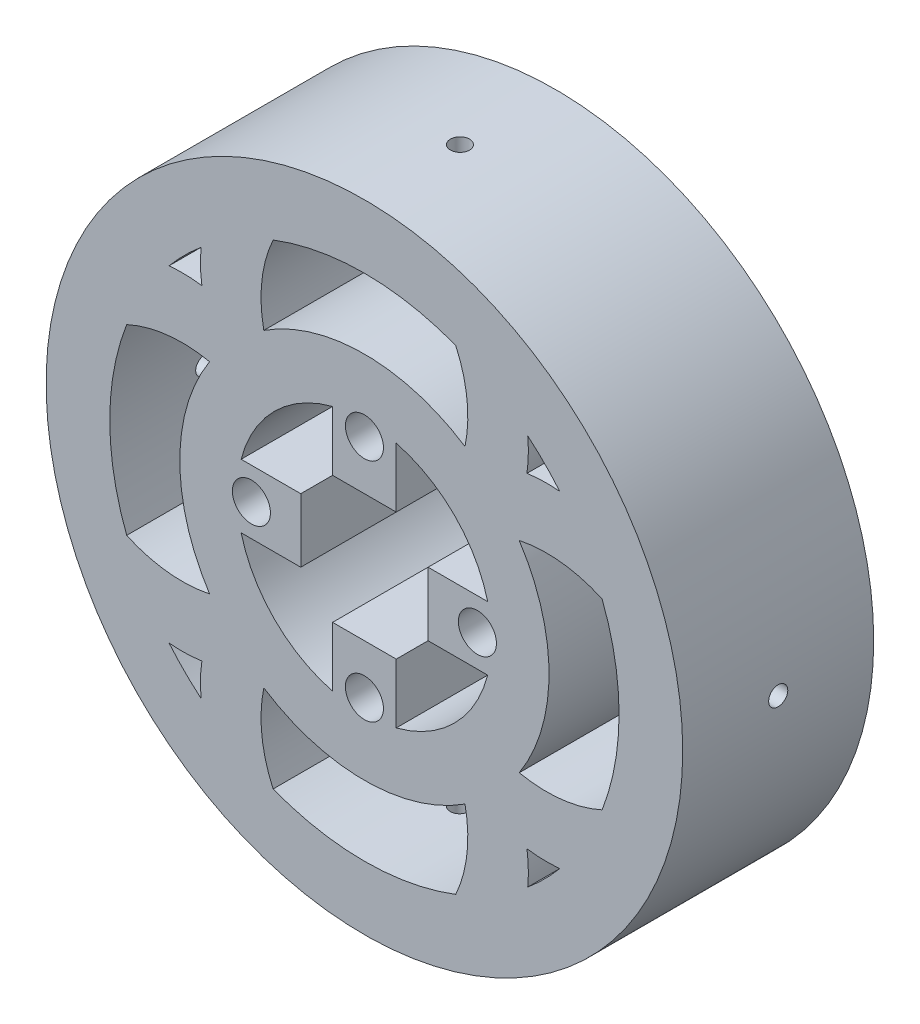
from build123d import *

# Parameters (mm, degrees)
SKETCH6_R                        = 29
SKETCH6_R_2                      = 20
INNER_RING_DEPTH                 = 30
MOTOR_CONNECTOR_CUT_DEPTH        = 30
SKETCH9_R                        = 50
SKETCH9_R_2                      = 29
OUTSIDE_RING_EXTRUSION_DEPTH     = 30
SKETCH12_R                       = 45
SKETCH12_R_2                     = 27.5
CUT_EXTRUDE6_DEPTH               = 38
CUT_EXTRUDE6_DEPTH_BACK          = 56
SKETCH8_R                        = 2.987
MOTOR_CONNECTOR_HOLES_DEPTH      = 27
MOTOR_CONNECTOR_HOLES_DEPTH_BACK = 41
SKETCH10_R                       = 27.404299948
PATTERN_DEPTH                    = 30
SKETCH13_R                       = 45
SKETCH13_R_2                     = 40
BOSS_EXTRUDE1_DEPTH              = 30
CUT_EXTRUDE7_DEPTH               = 13
CUT_EXTRUDE8_DEPTH               = 15
CUT_EXTRUDE9_DEPTH               = 17
CUT_EXTRUDE10_DEPTH              = 17


with BuildPart() as part:
    # Sketch6 → Inner Ring (new body)
    with BuildSketch(Plane.XY):
        Circle(SKETCH6_R)
        Circle(SKETCH6_R_2, mode=Mode.SUBTRACT)
    extrude(amount=-INNER_RING_DEPTH)

    # Sketch7 → Motor Connector Cut (add)
    with BuildSketch(Plane.XY):
        with BuildLine():
            ThreePointArc((20, 0), (19.840593925, 2.52008585), (19.364916731, 5))
            Line((19.364916731, 5), (9.999996731, 5))
            Line((9.999996731, 5), (9.999996731, -5))
            Line((9.999996731, -5), (19.364916731, -5))
            ThreePointArc((19.364916731, -5), (19.840593925, -2.52008585), (20, 0))
        make_face()
        with BuildLine():
            ThreePointArc((5, 19.364916731), (0, 20), (-5, 19.364916731))
            Line((-5, 19.364916731), (-5, 9.999996731))
            Line((-5, 9.999996731), (5, 9.999996731))
            Line((5, 9.999996731), (5, 19.364916731))
        make_face()
        with BuildLine():
            Line((-9.999996731, -5), (-9.999996731, 5))
            Line((-9.999996731, 5), (-19.364916731, 5))
            ThreePointArc((-19.364916731, 5), (-20, 0), (-19.364916731, -5))
            Line((-19.364916731, -5), (-9.999996731, -5))
        make_face()
        with BuildLine():
            Line((-5, -9.999996731), (-5, -19.364916731))
            ThreePointArc((-5, -19.364916731), (0, -20), (5, -19.364916731))
            Line((5, -19.364916731), (5, -9.999996731))
            Line((5, -9.999996731), (-5, -9.999996731))
        make_face()
    extrude(amount=-MOTOR_CONNECTOR_CUT_DEPTH)

    # Sketch9 → Outside Ring Extrusion (add)
    with BuildSketch(Plane.XY):
        Circle(SKETCH9_R)
        Circle(SKETCH9_R_2, mode=Mode.SUBTRACT)
    extrude(amount=-OUTSIDE_RING_EXTRUSION_DEPTH)

    # Sketch12 → Cut-Extrude6 (cut, two sides)
    with BuildSketch(Plane.XY) as cut_extrude6_sk:
        Circle(SKETCH12_R)
        Circle(SKETCH12_R_2, mode=Mode.SUBTRACT)
    extrude(amount=CUT_EXTRUDE6_DEPTH, mode=Mode.SUBTRACT)
    extrude(cut_extrude6_sk.sketch, amount=-CUT_EXTRUDE6_DEPTH_BACK, mode=Mode.SUBTRACT)

    # Sketch8 → Motor Connector Holes (cut, two sides)
    with BuildSketch(Plane.XY) as motor_connector_holes_sk:
        with Locations((0, 17.75)):
            Circle(SKETCH8_R)
        with Locations((17.75, 0)):
            Circle(SKETCH8_R)
        with Locations((0, -17.75)):
            Circle(SKETCH8_R)
        with Locations((-17.75, 0)):
            Circle(SKETCH8_R)
    extrude(amount=MOTOR_CONNECTOR_HOLES_DEPTH, mode=Mode.SUBTRACT)
    extrude(motor_connector_holes_sk.sketch, amount=-MOTOR_CONNECTOR_HOLES_DEPTH_BACK, mode=Mode.SUBTRACT)

    # Sketch10 → Pattern (add)
    with BuildSketch(Plane.XY):
        with BuildLine():
            ThreePointArc((24.317625284, 15.800414568), (34.856582319, 15.291767932), (43.817916626, 9.721954269))
            ThreePointArc((43.817916626, 9.721954269), (41.607188912, 16.793289988), (38.263814419, 23.404867172))
            ThreePointArc((38.263814419, 23.404867172), (32.064348025, 25.470287935), (25.530148518, 25.530148518))
            ThreePointArc((25.530148518, 25.530148518), (25.475284033, 32.034279432), (23.432821057, 38.209639668))
            ThreePointArc((23.432821057, 38.209639668), (20.212556871, 40.002288656), (16.856128399, 41.524812789))
            ThreePointArc((16.856128399, 41.524812789), (13.384732217, 42.767397097), (9.823095744, 43.720997037))
            ThreePointArc((9.823095744, 43.720997037), (15.312499865, 34.789679765), (15.800414568, 24.317625284))
            ThreePointArc((15.800414568, 24.317625284), (0, 29), (-15.800414568, 24.317625284))
            ThreePointArc((-15.800414568, 24.317625284), (-15.312499865, 34.789679765), (-9.823095744, 43.720997037))
            ThreePointArc((-9.823095744, 43.720997037), (-16.854754984, 41.52536899), (-23.432821057, 38.209639668))
            ThreePointArc((-23.432821057, 38.209639668), (-25.475284033, 32.034279432), (-25.530148518, 25.530148518))
            ThreePointArc((-25.530148518, 25.530148518), (-32.064348025, 25.470287935), (-38.263814419, 23.404867172))
            ThreePointArc((-38.263814419, 23.404867172), (-41.607188912, 16.793289988), (-43.817916626, 9.721954269))
            ThreePointArc((-43.817916626, 9.721954269), (-34.856582319, 15.291767932), (-24.317625284, 15.800414568))
            ThreePointArc((-24.317625284, 15.800414568), (-29, 0), (-24.317625284, -15.800414568))
            ThreePointArc((-24.317625284, -15.800414568), (-34.894848495, -15.279799844), (-43.87309253, -9.663767027))
            ThreePointArc((-43.87309253, -9.663767027), (-41.716263612, -16.713446711), (-38.435015504, -23.315212041))
            ThreePointArc((-38.435015504, -23.315212041), (-32.159621016, -25.454161245), (-25.530148518, -25.530148518))
            ThreePointArc((-25.530148518, -25.530148518), (-25.448803812, -32.190695038), (-23.285614603, -38.490703716))
            ThreePointArc((-23.285614603, -38.490703716), (-16.649731385, -41.799208281), (-9.559859326, -43.970581744))
            ThreePointArc((-9.559859326, -43.970581744), (-15.258354287, -34.962784804), (-15.800414568, -24.317625284))
            ThreePointArc((-15.800414568, -24.317625284), (0, -29), (15.800414568, -24.317625284))
            ThreePointArc((15.800414568, -24.317625284), (15.258354287, -34.962784804), (9.559859326, -43.970581744))
            ThreePointArc((9.559859326, -43.970581744), (16.649731385, -41.799208281), (23.285614603, -38.490703716))
            ThreePointArc((23.285614603, -38.490703716), (25.448803812, -32.190695038), (25.530148518, -25.530148518))
            ThreePointArc((25.530148518, -25.530148518), (32.159621016, -25.454161245), (38.435015504, -23.315212041))
            ThreePointArc((38.435015504, -23.315212041), (41.716263612, -16.713446711), (43.87309253, -9.663767027))
            ThreePointArc((43.87309253, -9.663767027), (34.894848495, -15.279799844), (24.317625284, -15.800414568))
            ThreePointArc((24.317625284, -15.800414568), (29, 0), (24.317625284, 15.800414568))
        make_face()
        with Locations((-0.095700052, 0)):
            Circle(SKETCH10_R, mode=Mode.SUBTRACT)
    extrude(amount=-PATTERN_DEPTH)

    # Sketch13 → Boss-Extrude1 (add)
    with BuildSketch(Plane.XY):
        Circle(SKETCH13_R)
        Circle(SKETCH13_R_2, mode=Mode.SUBTRACT)
    extrude(amount=-BOSS_EXTRUDE1_DEPTH)

    # Sketch14 → Cut-Extrude7 (cut)
    with BuildSketch(Plane(origin=(0, 50, 0), x_dir=(1, 0, 0), z_dir=(0, 1, 0))):
        with BuildLine():
            ThreePointArc((0, 16.5), (-1.5, 15), (0, 13.5))
            Line((0, 13.5), (0, 16.5))
        make_face()
        with BuildLine():
            Line((0, 16.5), (0, 13.5))
            ThreePointArc((0, 13.5), (1.060660172, 13.939339828), (1.5, 15))
            ThreePointArc((1.5, 15), (1.060660172, 16.060660172), (0, 16.5))
        make_face()
    extrude(amount=-CUT_EXTRUDE7_DEPTH, mode=Mode.SUBTRACT)

    # Sketch15 → Cut-Extrude8 (cut)
    with BuildSketch(Plane(origin=(0, -50, 0), x_dir=(1, 0, 0), z_dir=(0, 1, 0))):
        with BuildLine():
            ThreePointArc((0, 16.5), (-1.5, 15), (0, 13.5))
            Line((0, 13.5), (0, 16.5))
        make_face()
        with BuildLine():
            Line((0, 16.5), (0, 13.5))
            ThreePointArc((0, 13.5), (1.060660172, 13.939339828), (1.5, 15))
            ThreePointArc((1.5, 15), (1.060660172, 16.060660172), (0, 16.5))
        make_face()
    extrude(amount=CUT_EXTRUDE8_DEPTH, mode=Mode.SUBTRACT)

    # Sketch16 → Cut-Extrude9 (cut)
    with BuildSketch(Plane(origin=(-50, 0, 0), x_dir=(0, 0, -1), z_dir=(1, 0, 0))):
        with BuildLine():
            ThreePointArc((16.5, 0), (15, 1.5), (13.5, 0))
            Line((13.5, 0), (16.5, 0))
        make_face()
        with BuildLine():
            Line((16.5, 0), (13.5, 0))
            ThreePointArc((13.5, 0), (15, -1.5), (16.5, 0))
        make_face()
    extrude(amount=CUT_EXTRUDE9_DEPTH, mode=Mode.SUBTRACT)

    # Sketch17 → Cut-Extrude10 (cut)
    with BuildSketch(Plane(origin=(50, 0, 0), x_dir=(0, 0, -1), z_dir=(1, 0, 0))):
        with BuildLine():
            ThreePointArc((16.5, 0), (15, 1.5), (13.5, 0))
            Line((13.5, 0), (16.5, 0))
        make_face()
        with BuildLine():
            Line((16.5, 0), (13.5, 0))
            ThreePointArc((13.5, 0), (15, -1.5), (16.5, 0))
        make_face()
    extrude(amount=-CUT_EXTRUDE10_DEPTH, mode=Mode.SUBTRACT)


solid = part.part
